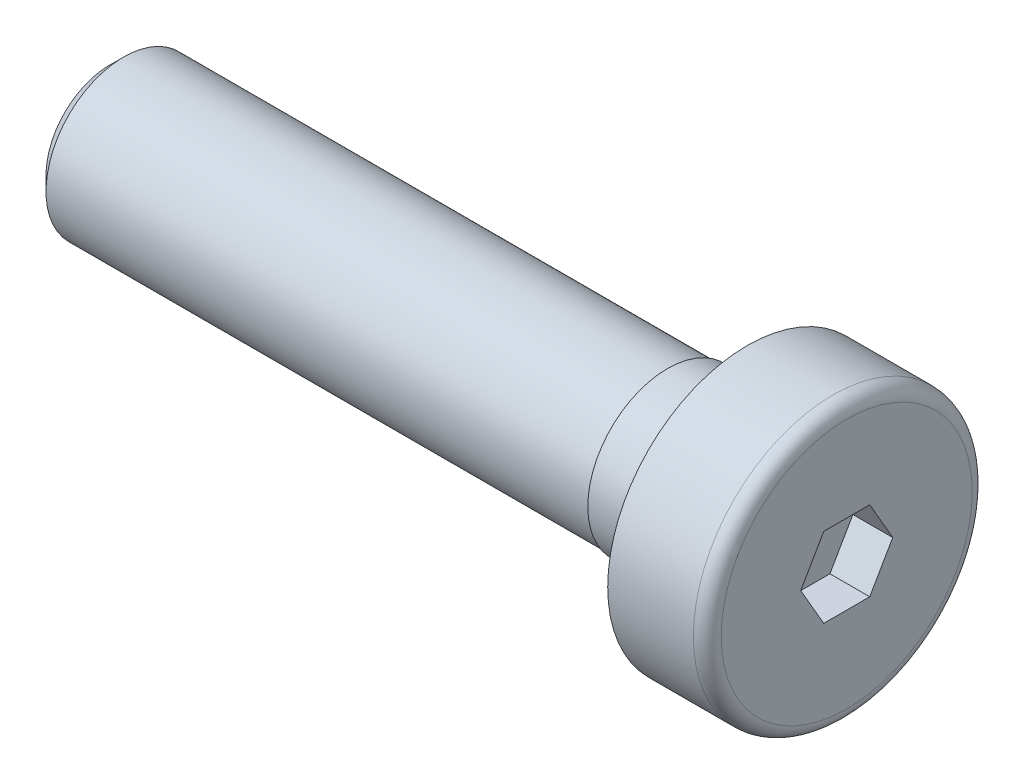
from build123d import *

# Parameters (mm, degrees)
SZKIC4_W                   = 14
SZKIC4_H                   = 0.05
SFAZOWANIE1_SIZE           = 0.35
ZAOKR_GLENIE1_R            = 0.35
WYTNIJ_WYCI_GNI_CIE1_DEPTH = 1


with BuildPart() as part:
    # Szkic1 → Obrót1 (revolve)
    with BuildSketch(Plane.XY):
        Polygon((0, 0), (0, 3.5), (-2.5, 3.5), (-2.5, 2), (-18.5, 2), (-18.5, 0), align=None)
    revolve(axis=Axis((-123.158940217, 0, 0), (1, 0, 0)))

    # Szkic4 → Wycięcie-obrót1 (revolve, cut)
    with BuildSketch(Plane(origin=(0, 0, 0), x_dir=(1, 0, 0), z_dir=(0, 1, 0))):
        with Locations((-11.5, -1.975)):
            Rectangle(SZKIC4_W, SZKIC4_H)
    revolve(axis=Axis((0, 0, 0), (-1, 0, 0)), mode=Mode.SUBTRACT)

    # Sfazowanie1
    sfazowanie1_edges = [part.edges().sort_by_distance(p)[0] for p in [
        (-18.5, 0, -1.95),
    ]]
    chamfer(sfazowanie1_edges, length=SFAZOWANIE1_SIZE)

    # Zaokrąglenie1
    zaokr_glenie1_edges = [part.edges().sort_by_distance(p)[0] for p in [
        (0, -3.5, 0),
    ]]
    fillet(zaokr_glenie1_edges, radius=ZAOKR_GLENIE1_R)

    # Szkic2 → Wytnij-wyciągnięcie1 (cut)
    with BuildSketch(Plane(origin=(0, 0, 0), x_dir=(0, 0, -1), z_dir=(1, 0, 0))):
        Polygon((1.154700538, 0), (0.577350269, 1), (-0.577350269, 1), (-1.154700538, 0), (-0.577350269, -1), (0.577350269, -1), align=None)
    extrude(amount=-WYTNIJ_WYCI_GNI_CIE1_DEPTH, mode=Mode.SUBTRACT)


solid = part.part
